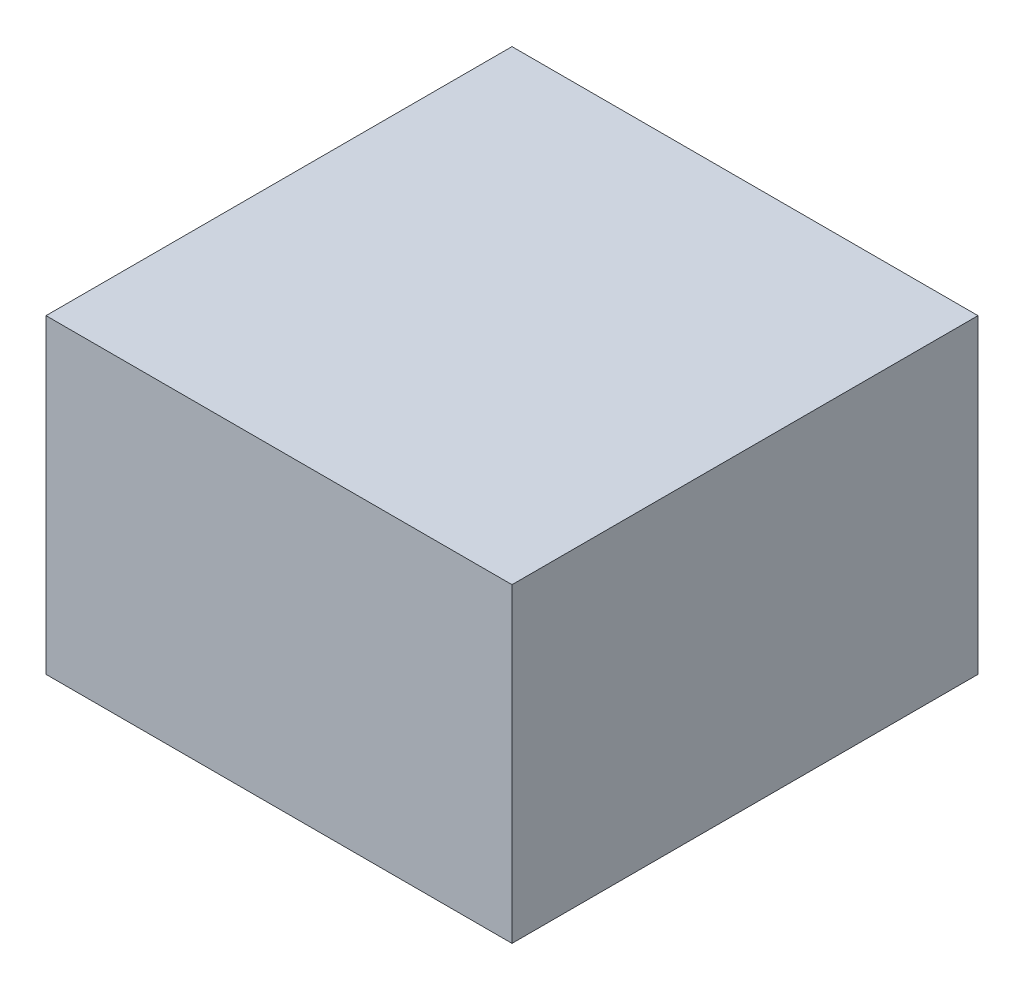
from build123d import *

# Parameters (mm, degrees)
SKETCH1_W      = 150
SKETCH1_H      = 150
EXTRUDE1_DEPTH = 100


with BuildPart() as part:
    # Sketch1 → Extrude1 (new body)
    with BuildSketch(Plane(origin=(0, 0, 0), x_dir=(1, 0, 0), z_dir=(0, 1, 0))):
        with Locations((-75, 75)):
            Rectangle(SKETCH1_W, SKETCH1_H)
    extrude(amount=EXTRUDE1_DEPTH)


solid = part.part
